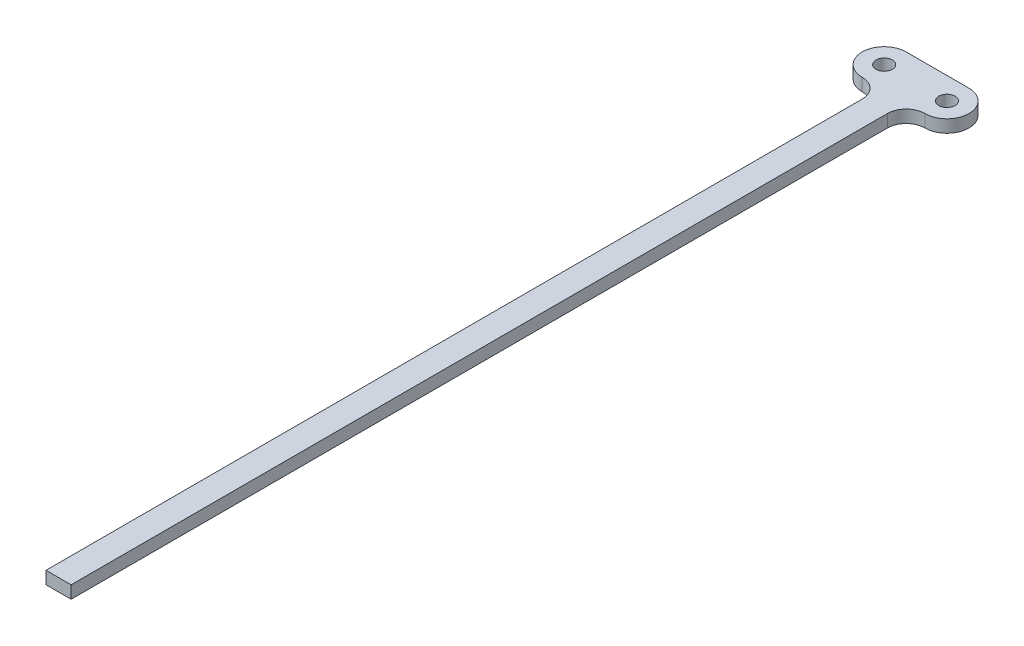
from build123d import *

# Parameters (mm, degrees)
SKETCH1_R           = 1.651
BOSS_EXTRUDE1_DEPTH = 2.54


with BuildPart() as part:
    # Sketch1 → Boss-Extrude1 (new body)
    with BuildSketch(Plane(origin=(0, 0, 0), x_dir=(1, 0, 0), z_dir=(0, 1, 0))):
        with BuildLine():
            Line((0, 0), (5.08, 0))
            Line((5.08, 0), (5.08, 165.1))
            ThreePointArc((5.08, 165.1), (6.195923164, 167.794076836), (8.89, 168.91))
            ThreePointArc((8.89, 168.91), (13.335, 173.355), (8.89, 177.8))
            Line((8.89, 177.8), (-3.81, 177.8))
            ThreePointArc((-3.81, 177.8), (-8.255, 173.355), (-3.81, 168.91))
            ThreePointArc((-3.81, 168.91), (-1.115923164, 167.794076836), (0, 165.1))
            Line((0, 165.1), (0, 0))
        make_face()
        with Locations((-3.81, 173.355)):
            Circle(SKETCH1_R, mode=Mode.SUBTRACT)
        with Locations((8.89, 173.355)):
            Circle(SKETCH1_R, mode=Mode.SUBTRACT)
    extrude(amount=BOSS_EXTRUDE1_DEPTH)


solid = part.part
